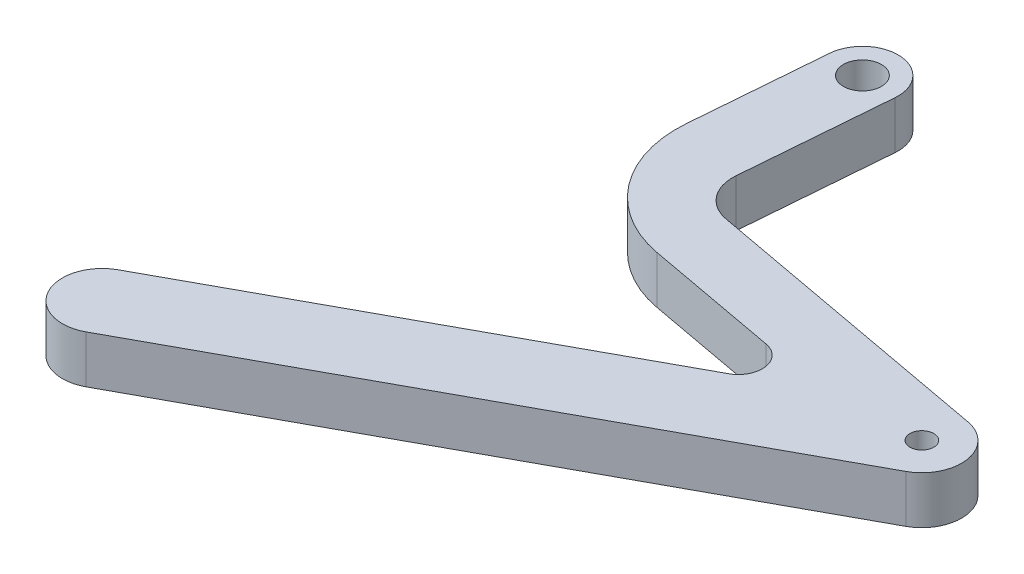
from build123d import *

# Parameters (mm, degrees)
SKETCH1_R           = 1.5
SKETCH1_R_2         = 2.4
BOSS_EXTRUDE1_DEPTH = 6


with BuildPart() as part:
    # Sketch1 → Boss-Extrude1 (new body)
    with BuildSketch(Plane(origin=(0, 0, 0), x_dir=(1, 0, 0), z_dir=(0, 1, 0))):
        with BuildLine():
            Line((-19.436129881, 35.921169676), (-20.784472899, 19.250484474))
            ThreePointArc((-20.784472899, 19.250484474), (-17.739772521, 8.917849876), (-8.554847577, 3.290177898))
            Line((-8.554847577, 3.290177898), (8.303819749, 0.179771806))
            ThreePointArc((8.303819749, 0.179771806), (10.722077148, -2.298002723), (9.194413259, -5.405023565))
            Line((9.194413259, -5.405023565), (-40.652031907, -32.553428604))
            ThreePointArc((-40.652031907, -32.553428604), (-42.651504917, -39.335913966), (-35.869019555, -41.335386976))
            Line((-35.869019555, -41.335386976), (31.012382829, -4.909050143))
            ThreePointArc((31.012382829, -4.909050143), (33.55848931, 0.269317926), (29.528060312, 4.398942141))
            Line((29.528060312, 4.398942141), (-7.891068482, 11.302731386))
            ThreePointArc((-7.891068482, 11.302731386), (-10.95271013, 13.178622045), (-11.967610256, 16.622833578))
            Line((-11.967610256, 16.622833578), (-10.465424103, 35.195609308))
            ThreePointArc((-10.465424103, 35.195609308), (-14.587996808, 40.043742381), (-19.436129881, 35.921169676))
        make_face()
        with Locations((28.620876654, -0.518070957)):
            Circle(SKETCH1_R, mode=Mode.SUBTRACT)
        with Locations((-14.950776992, 35.558389492)):
            Circle(SKETCH1_R_2, mode=Mode.SUBTRACT)
    extrude(amount=BOSS_EXTRUDE1_DEPTH)


solid = part.part
